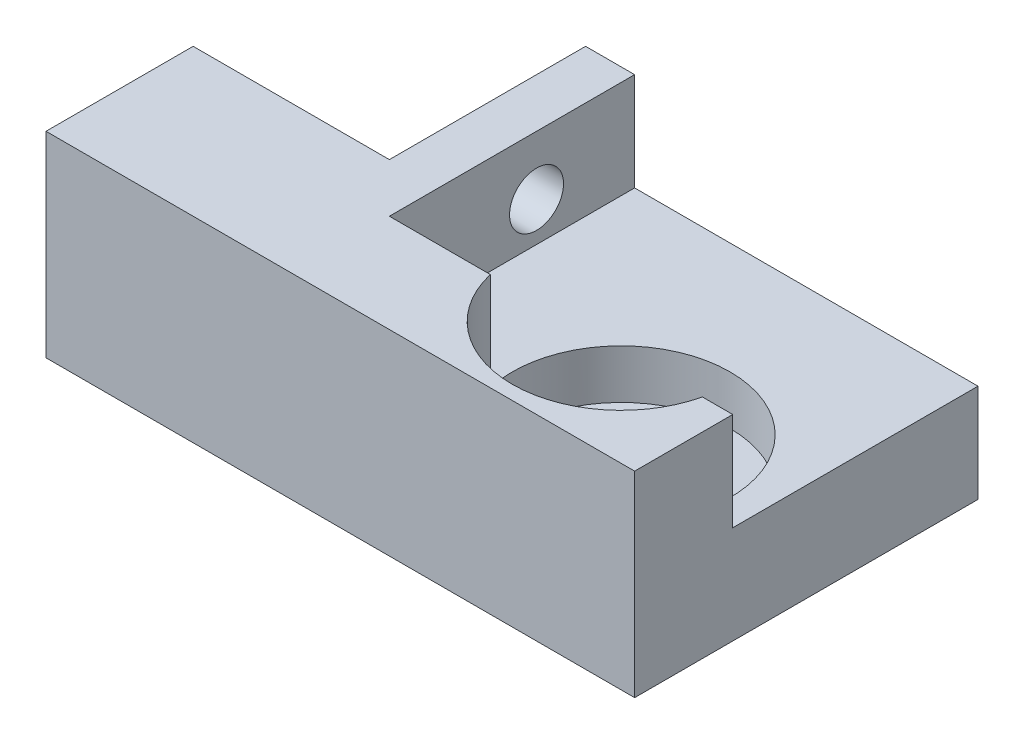
from build123d import *

# Parameters (mm, degrees)
BOSS_EXTRUDE1_DEPTH = 20
SKETCH2_W           = 35
SKETCH2_H           = 25
CUT_EXTRUDE1_DEPTH  = 10
CUT_EXTRUDE2_START  = 20
SKETCH3_R           = 11.1
CUT_EXTRUDE2_DEPTH  = 25
SKETCH4_R           = 5
CUT_EXTRUDE3_DEPTH  = 6
SKETCH5_R           = 2.75
CUT_EXTRUDE4_DEPTH  = 26


with BuildPart() as part:
    # Sketch1 → Boss-Extrude1 (new body)
    with BuildSketch(Plane(origin=(0, 0, 0), x_dir=(1, 0, 0), z_dir=(0, 1, 0))):
        Polygon((0, 0), (60, 0), (60, 35), (20, 35), (20, 15), (0, 15), align=None)
    extrude(amount=BOSS_EXTRUDE1_DEPTH)

    # Sketch2 → Cut-Extrude1 (cut)
    with BuildSketch(Plane(origin=(0, 20, 0), x_dir=(1, 0, 0), z_dir=(0, 1, 0))):
        with Locations((42.5, 22.5)):
            Rectangle(SKETCH2_W, SKETCH2_H)
    extrude(amount=-CUT_EXTRUDE1_DEPTH, mode=Mode.SUBTRACT)

    # Sketch3 → Cut-Extrude2 (cut)
    with BuildSketch(Plane(origin=(0, 10, 0), x_dir=(1, 0, 0), z_dir=(0, 1, 0)).offset(CUT_EXTRUDE2_START)):
        with Locations((46.1, 12.525762493)):
            Circle(SKETCH3_R)
    extrude(amount=-CUT_EXTRUDE2_DEPTH, mode=Mode.SUBTRACT)

    # Sketch4 → Cut-Extrude3 (cut, through all)
    with BuildSketch(Plane(origin=(0, 5, 0), x_dir=(1, 0, 0), z_dir=(0, 1, 0))):
        with Locations((46.1, 12.525762493)):
            Circle(SKETCH4_R)
    extrude(amount=-CUT_EXTRUDE3_DEPTH, mode=Mode.SUBTRACT)

    # Sketch5 → Cut-Extrude4 (cut, through all)
    with BuildSketch(Plane(origin=(25, 0, 0), x_dir=(0, 0, -1), z_dir=(1, 0, 0))):
        with Locations((25, 14)):
            Circle(SKETCH5_R)
    extrude(amount=-CUT_EXTRUDE4_DEPTH, mode=Mode.SUBTRACT)


solid = part.part
